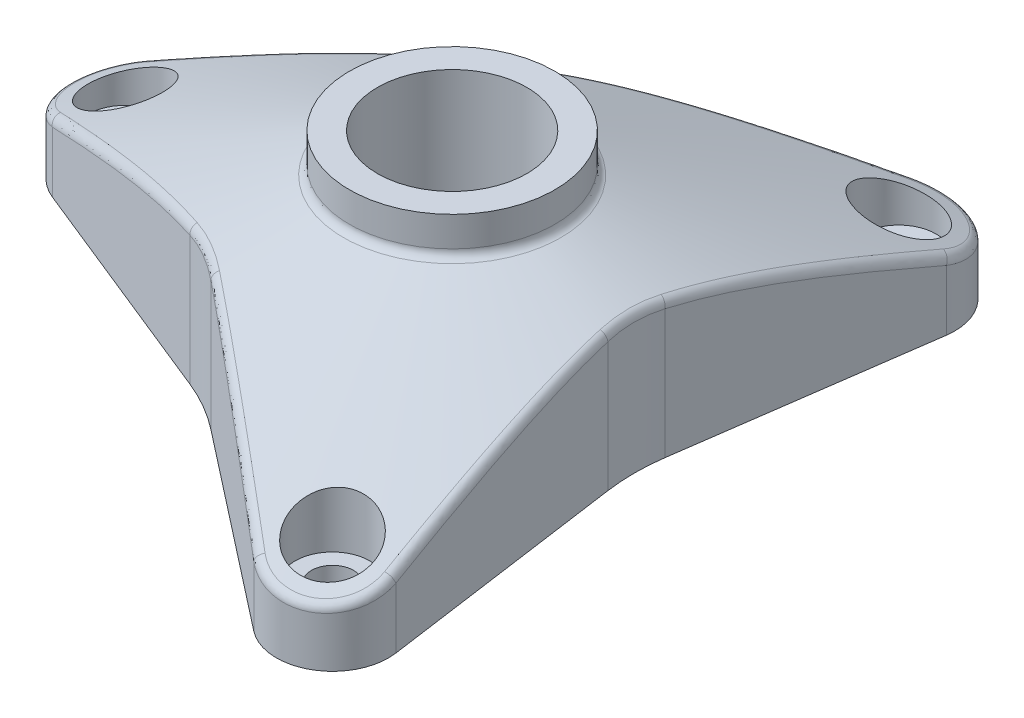
from build123d import *

# Parameters (mm, degrees)
BOSS_EXTRUDE1_DEPTH = 22
SKETCH3_R           = 8
CUT_EXTRUDE1_DEPTH  = 30
SKETCH4_R           = 2.25
CUT_EXTRUDE2_DEPTH  = 4
SKETCH5_R           = 4
CUT_EXTRUDE3_DEPTH  = 7
CIRPATTERN1_COUNT   = 3
FILLET1_R           = 1


with BuildPart() as part:
    # Sketch1 → Boss-Extrude1 (new body)
    with BuildSketch(Plane(origin=(0, 0, 0), x_dir=(1, 0, 0), z_dir=(0, 1, 0))):
        with BuildLine():
            Line((-37.24763956, -5.563103127), (-12.51628213, -15.55522013))
            ThreePointArc((-12.51628213, -15.55522013), (-9.757627186, -16.900706047), (-7.213074728, -18.617028351))
            Line((-7.213074728, -18.617028351), (13.806031148, -35.038953654))
            ThreePointArc((13.806031148, -35.038953654), (20.5, -35.507041555), (23.441608412, -29.475850527))
            Line((23.441608412, -29.475850527), (19.729356859, -3.061808221))
            ThreePointArc((19.729356859, -3.061808221), (19.515254371, 0), (19.729356859, 3.061808221))
            Line((19.729356859, 3.061808221), (23.441608412, 29.475850527))
            ThreePointArc((23.441608412, 29.475850527), (20.5, 35.507041555), (13.806031148, 35.038953654))
            Line((13.806031148, 35.038953654), (-7.213074728, 18.617028351))
            ThreePointArc((-7.213074728, 18.617028351), (-9.757627186, 16.900706047), (-12.51628213, 15.55522013))
            Line((-12.51628213, 15.55522013), (-37.24763956, 5.563103127))
            ThreePointArc((-37.24763956, 5.563103127), (-41, 0), (-37.24763956, -5.563103127))
        make_face()
    extrude(amount=BOSS_EXTRUDE1_DEPTH)

    # Sketch2 → Cut-Revolve1 (revolve, cut)
    with BuildSketch(Plane.XY, mode=Mode.PRIVATE) as cut_revolve1_sk:
        Polygon((0, 22), (-11, 22), (-11, 18.120786775), (-41, 6), (-46.06650448, 30.67311148), (0, 30.67311148), align=None)
    revolve(cut_revolve1_sk.sketch.rotate(Axis((0, 0, 0), (0, 1, 0)), 270), axis=Axis((0, 0, 0), (0, 1, 0)), mode=Mode.SUBTRACT)  # turned: the seam where the file's is

    # Sketch3 → Cut-Extrude1 (cut)
    with BuildSketch(Plane(origin=(0, 22, 0), x_dir=(1, 0, 0), z_dir=(0, 1, 0))):
        with Locations(Location((0, 0, 0), (0, 0, 270))):  # turned: the seam where the file's is
            Circle(SKETCH3_R)
    extrude(amount=-CUT_EXTRUDE1_DEPTH, mode=Mode.SUBTRACT)

    # Sketch4 → Cut-Extrude2 (cut)
    with BuildSketch(Plane.XZ):
        with Locations(Location((17.5, 30.310889132, 0), (0, 0, 270))):  # turned: the seam where the file's is
            Circle(SKETCH4_R)
    cut_extrude2 = extrude(amount=-CUT_EXTRUDE2_DEPTH, mode=Mode.SUBTRACT)

    # Sketch5 → Cut-Extrude3 (cut)
    with BuildSketch(Plane.XZ.offset(-4)):
        with Locations(Location((17.5, 30.310889132, 0), (0, 0, 270))):  # turned: the seam where the file's is
            Circle(SKETCH5_R)
    cut_extrude3 = extrude(amount=-CUT_EXTRUDE3_DEPTH, mode=Mode.SUBTRACT)

    # CirPattern1: Cut-Extrude2, Cut-Extrude3 ×3 about axis
    cirpattern1_axis = Axis((0, 0, 0), (0, 1, 0))
    add([cut_extrude2.rotate(cirpattern1_axis, i * 360 / CIRPATTERN1_COUNT) for i in range(1, CIRPATTERN1_COUNT)], mode=Mode.SUBTRACT)
    add([cut_extrude3.rotate(cirpattern1_axis, i * 360 / CIRPATTERN1_COUNT) for i in range(1, CIRPATTERN1_COUNT)], mode=Mode.SUBTRACT)

    # Fillet1
    fillet1_edges = [part.edges().sort_by_distance(p)[0] for p in [
        (-25.042219903, 11.59484824, -10.494412766),
        (-41, 6, 0),
        (20.499999997, 6, -35.507041557),
        (6.94907072, 10.248612696, -29.68170903),
        (-9.757627186, 14.68040069, -16.900706047),
        (-25.042219903, 11.59484824, 10.494412766),
        (-9.757627185, 14.68040069, 16.900706047),
        (3.432681898, 11.59484824, 26.934404987),
        (20.5, 6, 35.507041555),
        (21.609538005, 11.59484824, 16.43999222),
        (19.515254371, 14.68040069, 0),
        (21.609538005, 11.59484824, -16.43999222),
        (0, 18.120786775, 11),
    ]]
    fillet(fillet1_edges, radius=FILLET1_R)


solid = part.part
